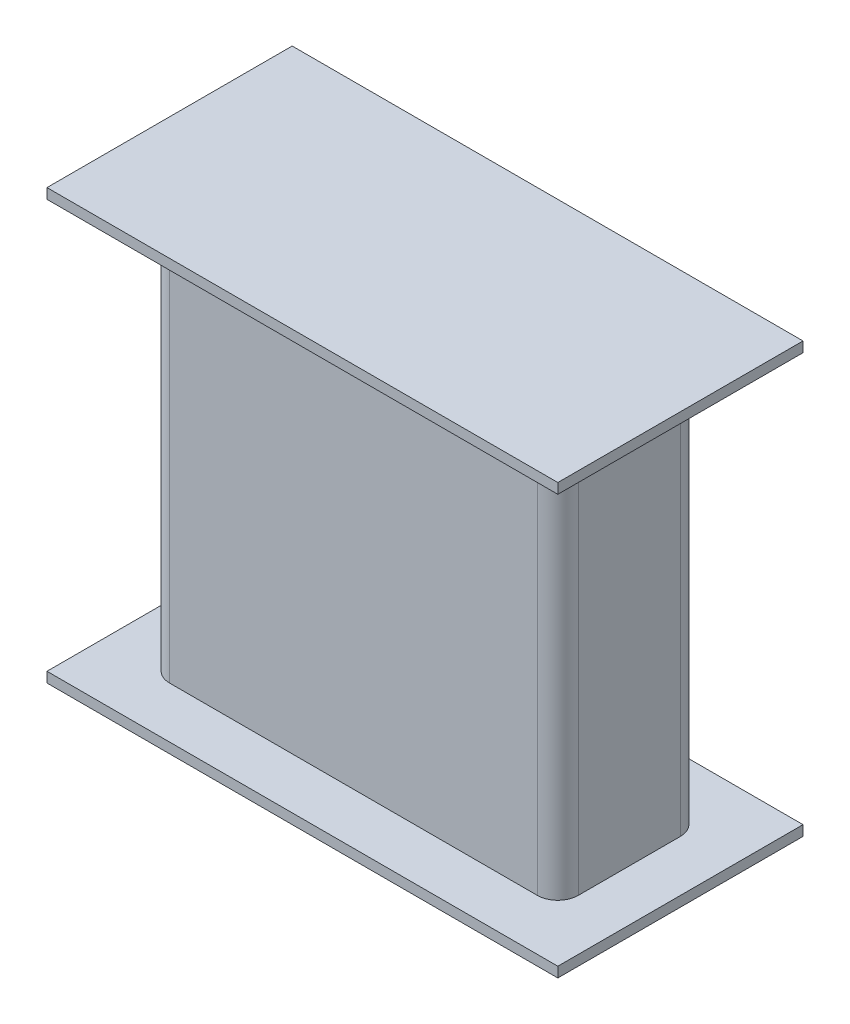
from build123d import *

# Parameters (mm, degrees)
SKETCH_1_W          = 40
SKETCH_1_H          = 14
EXTRUDE_1_DEPTH     = 40
SKETCH_6_W          = 36
SKETCH_6_H          = 10
CUT_EXTRUDE_2_DEPTH = 41
SKETCH_15_OUTSIDE_W = 53.656
SKETCH_15_OUTSIDE_H = 27.656
CUT_EXTRUDE_5_DEPTH = 41
SKETCH_16_W         = 50
SKETCH_16_H         = 24
EXTRUDE_2_DEPTH     = 1
SKETCH_17_W         = 50
SKETCH_17_H         = 24
EXTRUDE_3_DEPTH     = 1
SKETCH_18_W         = 36
SKETCH_18_H         = 10
CUT_EXTRUDE_6_DEPTH = 1


with BuildPart() as part:
    # 草图1 → 凸台-拉伸1 (new body)
    with BuildSketch(Plane(origin=(0, 0, 0), x_dir=(1, 0, 0), z_dir=(0, 1, 0))):
        with Locations((20, 7)):
            Rectangle(SKETCH_1_W, SKETCH_1_H)
    extrude(amount=EXTRUDE_1_DEPTH)

    # 草图6 → 切除-拉伸2 (cut, through all)
    with BuildSketch(Plane(origin=(0, 40, 0), x_dir=(1, 0, 0), z_dir=(0, 1, 0))):
        with Locations((20, 7)):
            Rectangle(SKETCH_6_W, SKETCH_6_H)
    extrude(amount=-CUT_EXTRUDE_2_DEPTH, mode=Mode.SUBTRACT)

    # 草图15 outside → 切除-拉伸5 (cut, through all)
    with BuildSketch(Plane.XZ):
        with Locations((20, -7)):
            Rectangle(SKETCH_15_OUTSIDE_W, SKETCH_15_OUTSIDE_H)
        with BuildLine():
            Line((2, -14), (38, -14))
            ThreePointArc((38, -14), (39.414213562, -13.414213562), (40, -12))
            Line((40, -12), (40, -2))
            ThreePointArc((40, -2), (39.414213562, -0.585786438), (38, 0))
            Line((38, 0), (2, 0))
            ThreePointArc((2, 0), (0.585786438, -0.585786438), (0, -2))
            Line((0, -2), (0, -12))
            ThreePointArc((0, -12), (0.585786438, -13.414213562), (2, -14))
        make_face(mode=Mode.SUBTRACT)
    extrude(amount=-CUT_EXTRUDE_5_DEPTH, mode=Mode.SUBTRACT)

    # 草图16 → 凸台-拉伸2 (add)
    with BuildSketch(Plane(origin=(0, 40, 0), x_dir=(1, 0, 0), z_dir=(0, 1, 0))):
        with Locations((20, 7)):
            Rectangle(SKETCH_16_W, SKETCH_16_H)
    extrude(amount=EXTRUDE_2_DEPTH)

    # 草图17 → 凸台-拉伸3 (add)
    with BuildSketch(Plane.XZ):
        with Locations((20, -7)):
            Rectangle(SKETCH_17_W, SKETCH_17_H)
    extrude(amount=EXTRUDE_3_DEPTH)

    # 草图18 → 切除-拉伸6 (cut)
    with BuildSketch(Plane(origin=(0, -1, 0), x_dir=(-1, 0, 0), z_dir=(0, -1, 0))):
        with Locations((-20, 7)):
            Rectangle(SKETCH_18_W, SKETCH_18_H)
    extrude(amount=-CUT_EXTRUDE_6_DEPTH, mode=Mode.SUBTRACT)


solid = part.part
